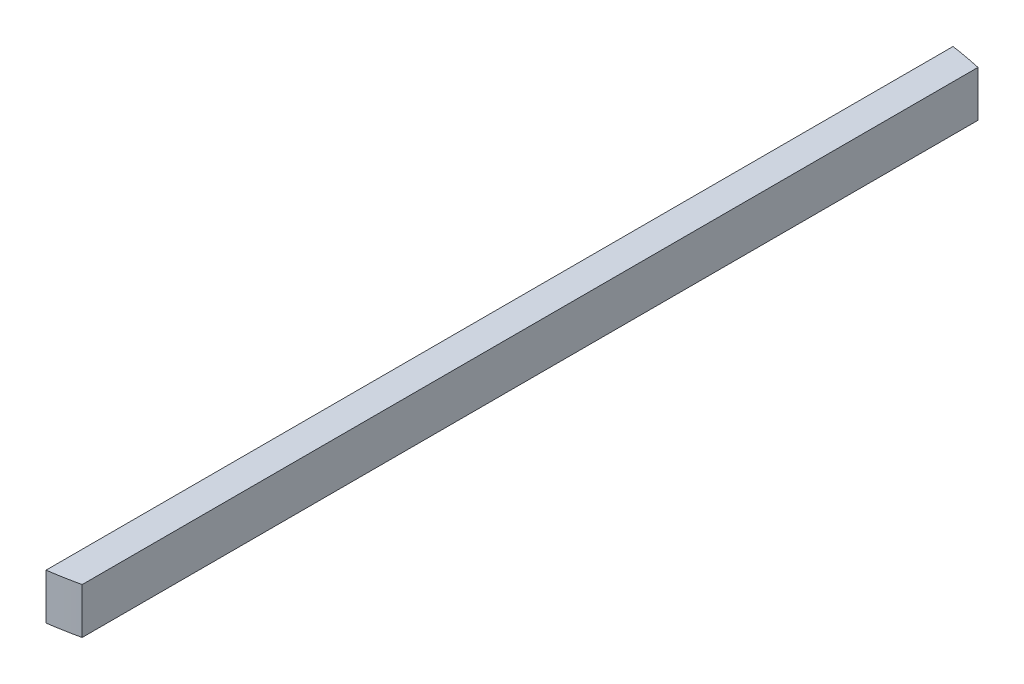
from build123d import *

# Parameters (mm, degrees)
BOSS_EXTRUDE1_DEPTH = 4.7625


with BuildPart() as part:
    # Sketch2 → Boss-Extrude1 (new body)
    with BuildSketch(Plane(origin=(0, 0, 0), x_dir=(1, 0, 0), z_dir=(0, 1, 0))):
        with BuildLine():
            Line((10.16, -46.528647358), (10.16, 46.528647358))
            ThreePointArc((10.16, 46.528647358), (8.577426405, 46.846220565), (6.985, 47.109981957))
            Line((6.985, 47.109981957), (6.985, -47.109981957))
            ThreePointArc((6.985, -47.109981957), (8.577426405, -46.846220565), (10.16, -46.528647358))
        make_face()
    extrude(amount=BOSS_EXTRUDE1_DEPTH)


solid = part.part
